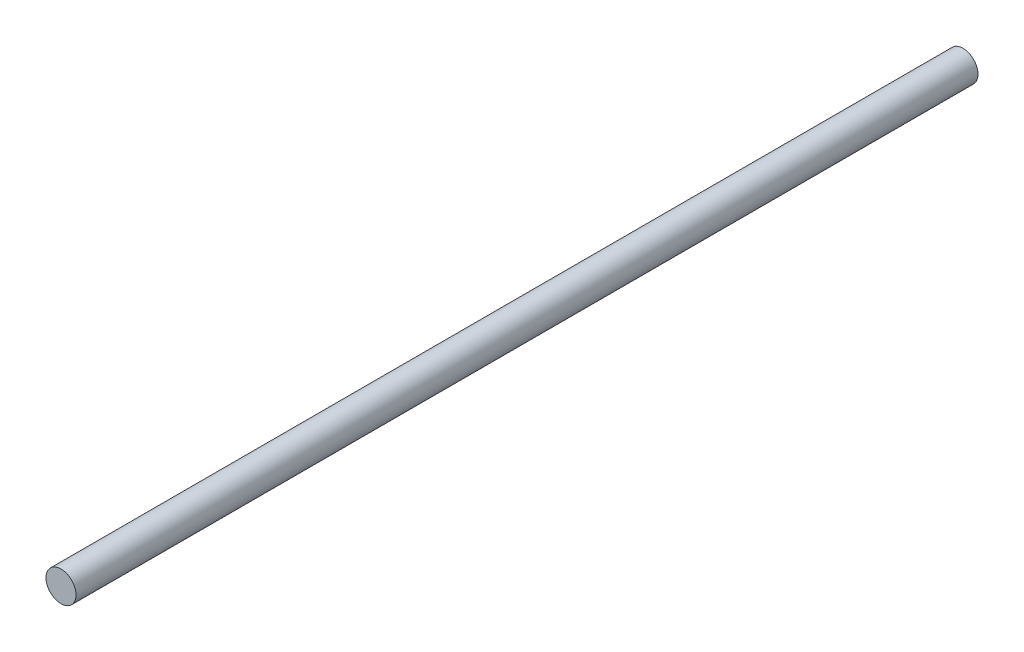
from build123d import *

# Parameters (mm, degrees)
SKETCH1_R           = 6.35
BOSS_EXTRUDE1_DEPTH = 190.5


with BuildPart() as part:
    # Sketch1 → Boss-Extrude1 (new body, symmetric)
    with BuildSketch(Plane.XY):
        Circle(SKETCH1_R)
    extrude(amount=BOSS_EXTRUDE1_DEPTH, both=True)


solid = part.part
